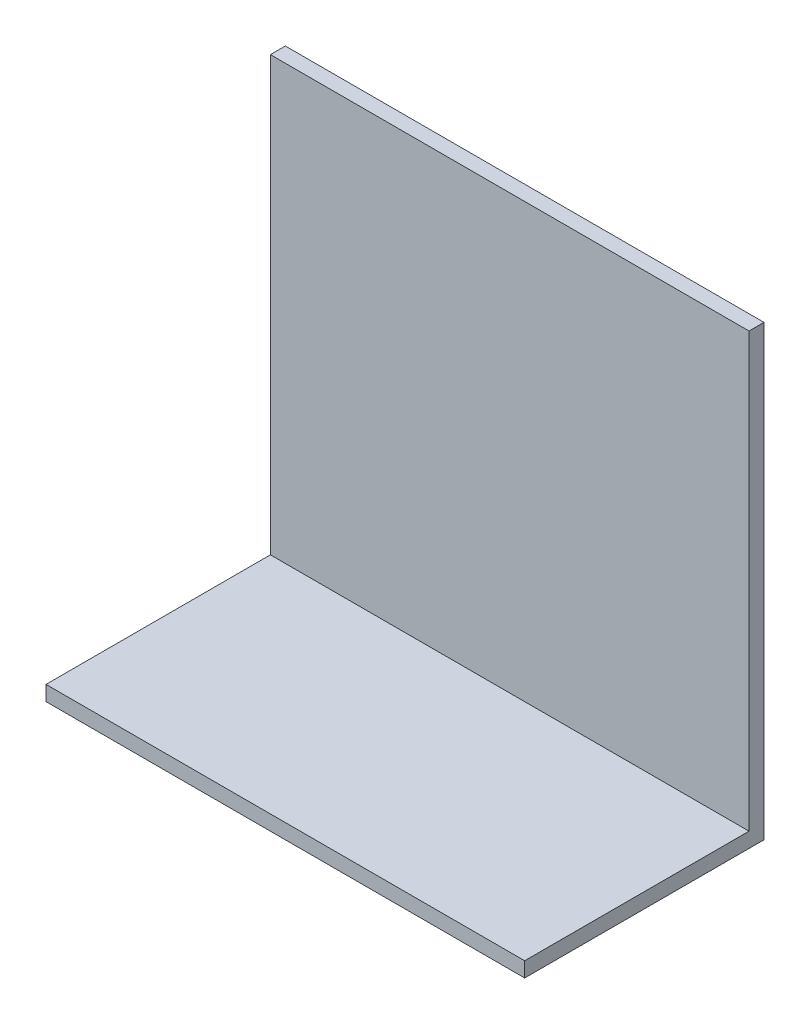
from build123d import *

# Parameters (mm, degrees)
SKETCH1_W           = 101.6
SKETCH1_H           = 95.123
BOSS_EXTRUDE1_DEPTH = 3.175
SKETCH2_W           = 101.6
SKETCH2_H           = 50.8
BOSS_EXTRUDE2_DEPTH = 3.175


with BuildPart() as part:
    # Sketch1 → Boss-Extrude1 (new body)
    with BuildSketch(Plane.XY):
        with Locations((4.584153793, 18.821494918)):
            Rectangle(SKETCH1_W, SKETCH1_H)
    extrude(amount=BOSS_EXTRUDE1_DEPTH)

    # Sketch2 → Boss-Extrude2 (add)
    with BuildSketch(Plane(origin=(0, -28.740005082, 0), x_dir=(-1, 0, 0), z_dir=(0, -1, 0))):
        with Locations((-4.584153793, -25.4)):
            Rectangle(SKETCH2_W, SKETCH2_H)
    extrude(amount=-BOSS_EXTRUDE2_DEPTH)


solid = part.part
